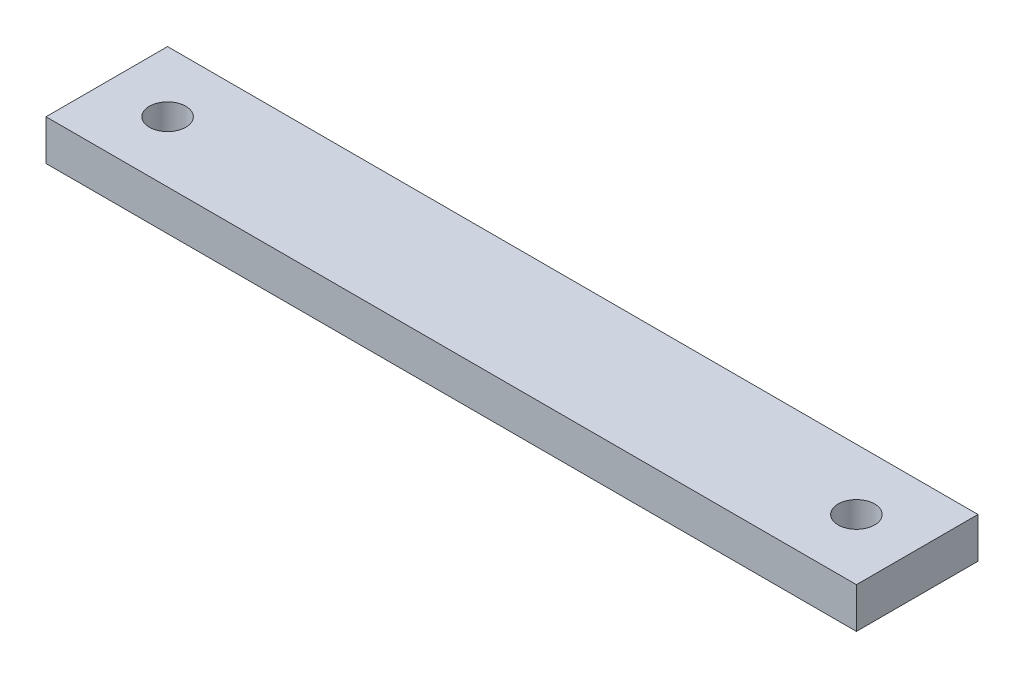
from build123d import *

# Parameters (mm, degrees)
SKETCH1_W           = 200
SKETCH1_H           = 30
SKETCH1_R           = 4.5
BOSS_EXTRUDE1_DEPTH = 10


with BuildPart() as part:
    # Sketch1 → Boss-Extrude1 (new body)
    with BuildSketch(Plane(origin=(0, 0, 0), x_dir=(1, 0, 0), z_dir=(0, 1, 0))):
        with Locations((-100, 15)):
            Rectangle(SKETCH1_W, SKETCH1_H)
        with Locations((-185, 15)):
            Circle(SKETCH1_R, mode=Mode.SUBTRACT)
        with Locations((-15, 15)):
            Circle(SKETCH1_R, mode=Mode.SUBTRACT)
    extrude(amount=BOSS_EXTRUDE1_DEPTH)


solid = part.part
